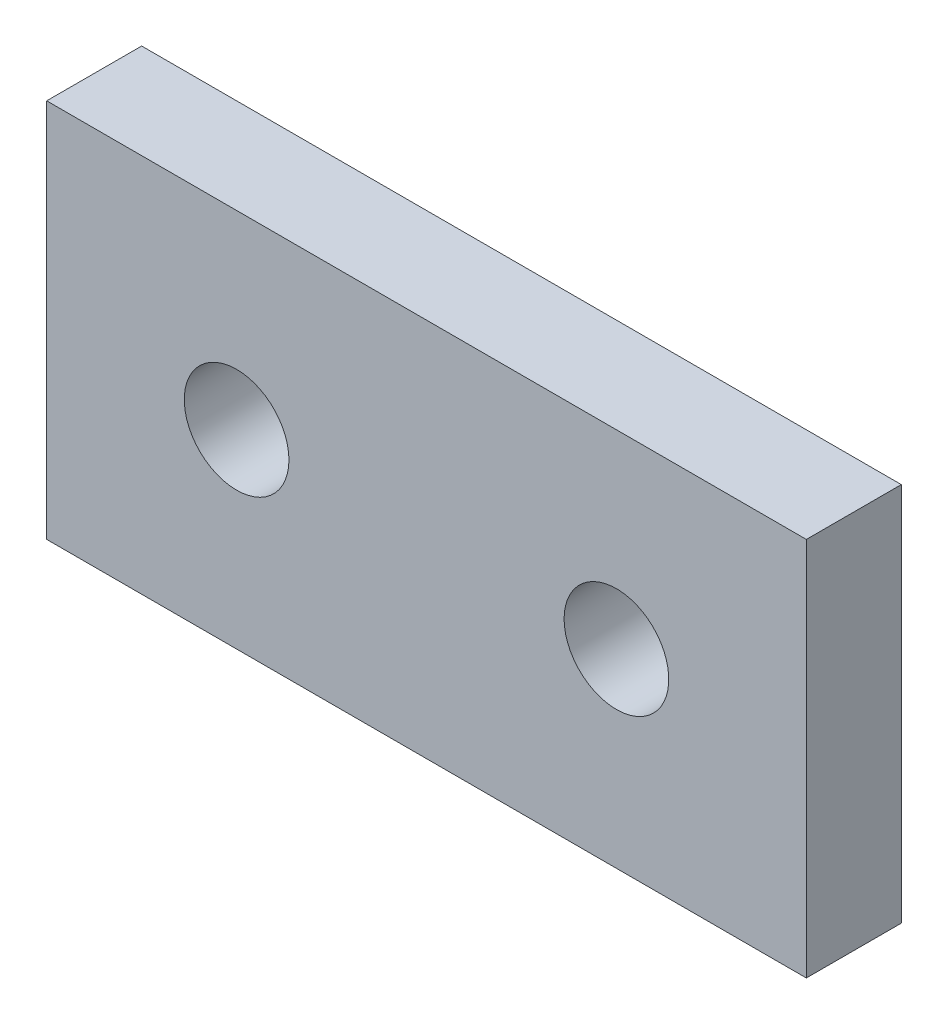
from build123d import *

# Parameters (mm, degrees)
SKETCH1_W           = 50.8
SKETCH1_H           = 25.4
BOSS_EXTRUDE1_DEPTH = 6.35
SKETCH2_R           = 3.5
CUT_EXTRUDE1_DEPTH  = 6.35


with BuildPart() as part:
    # Sketch1 → Boss-Extrude1 (new body)
    with BuildSketch(Plane.XY):
        with Locations((25.4, 12.7)):
            Rectangle(SKETCH1_W, SKETCH1_H)
    extrude(amount=BOSS_EXTRUDE1_DEPTH)

    # Sketch2 → Cut-Extrude1 (cut)
    with BuildSketch(Plane.XY.offset(6.35)):
        with Locations((12.7, 12.7)):
            Circle(SKETCH2_R)
        with Locations((38.1, 12.7)):
            Circle(SKETCH2_R)
    extrude(amount=-CUT_EXTRUDE1_DEPTH, mode=Mode.SUBTRACT)


solid = part.part
